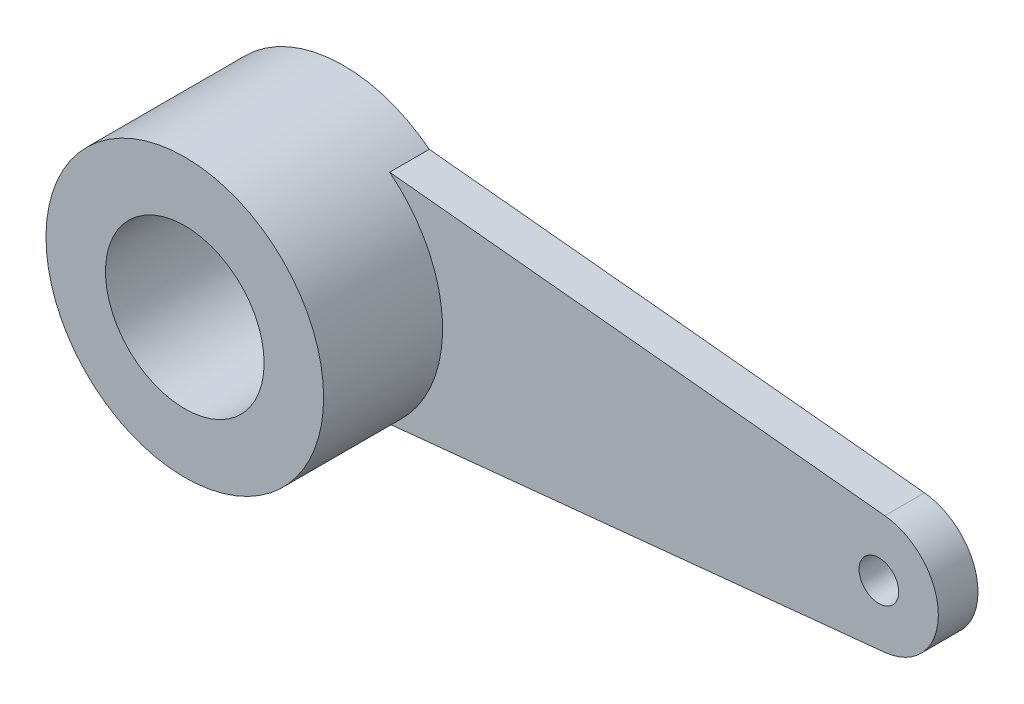
from build123d import *

# Parameters (mm, degrees)
SKETCH_1_R      = 2
SKETCH_1_R_2    = 0.5
EXTRUDE_2_DEPTH = 1
SKETCH_2_R      = 3.5
SKETCH_2_R_2    = 2
EXTRUDE_3_DEPTH = 3


with BuildPart() as part:
    # 草图1 → 凸台-拉伸2 (new body)
    with BuildSketch(Plane.XY):
        with BuildLine():
            Line((14.650323726, 1.492448585), (2.165063509, 2.75))
            ThreePointArc((2.165063509, 2.75), (-3.5, 0), (2.165063509, -2.75))
            Line((2.165063509, -2.75), (14.650323726, -1.492448585))
            ThreePointArc((14.650323726, -1.492448585), (16, 0), (14.650323726, 1.492448585))
        make_face()
        Circle(SKETCH_1_R, mode=Mode.SUBTRACT)
        with Locations((14.5, 0)):
            Circle(SKETCH_1_R_2, mode=Mode.SUBTRACT)
    extrude(amount=EXTRUDE_2_DEPTH)

    # 草图2 → 凸台-拉伸3 (add)
    with BuildSketch(Plane.XY.offset(1)):
        Circle(SKETCH_2_R)
        Circle(SKETCH_2_R_2, mode=Mode.SUBTRACT)
    extrude(amount=EXTRUDE_3_DEPTH)


solid = part.part
